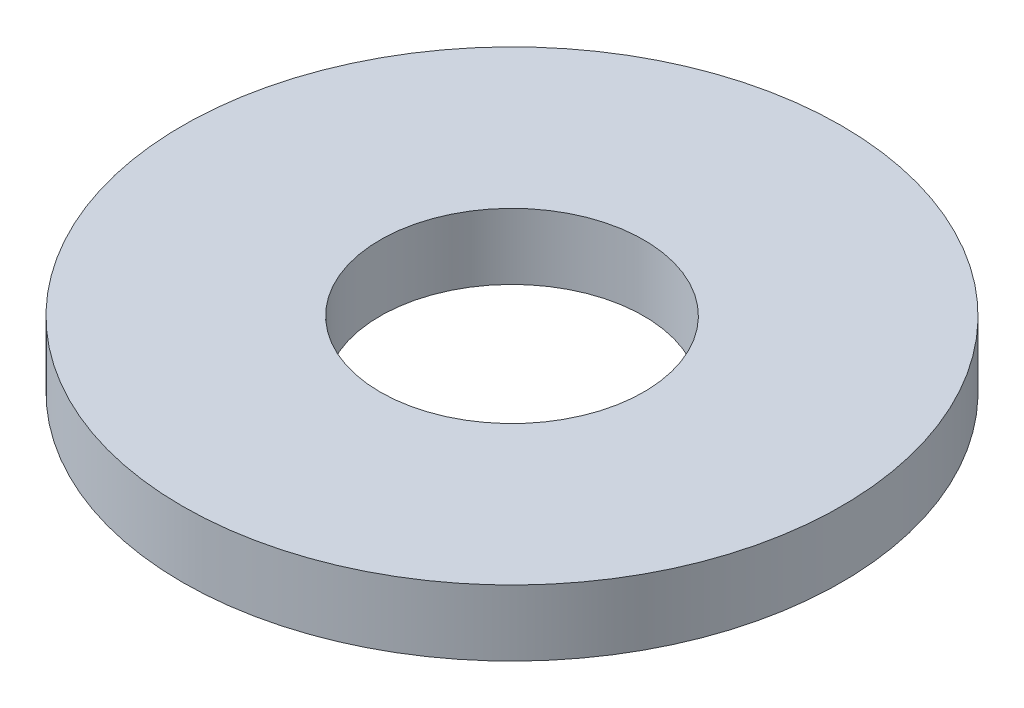
from build123d import *

# Parameters (mm, degrees)
SKETCH1_R           = 5
SKETCH1_R_2         = 2
BOSS_EXTRUDE1_DEPTH = 1


with BuildPart() as part:
    # Sketch1 → Boss-Extrude1 (new body)
    with BuildSketch(Plane(origin=(0, 0, 0), x_dir=(1, 0, 0), z_dir=(0, 1, 0))):
        Circle(SKETCH1_R)
        Circle(SKETCH1_R_2, mode=Mode.SUBTRACT)
    extrude(amount=BOSS_EXTRUDE1_DEPTH)


solid = part.part
